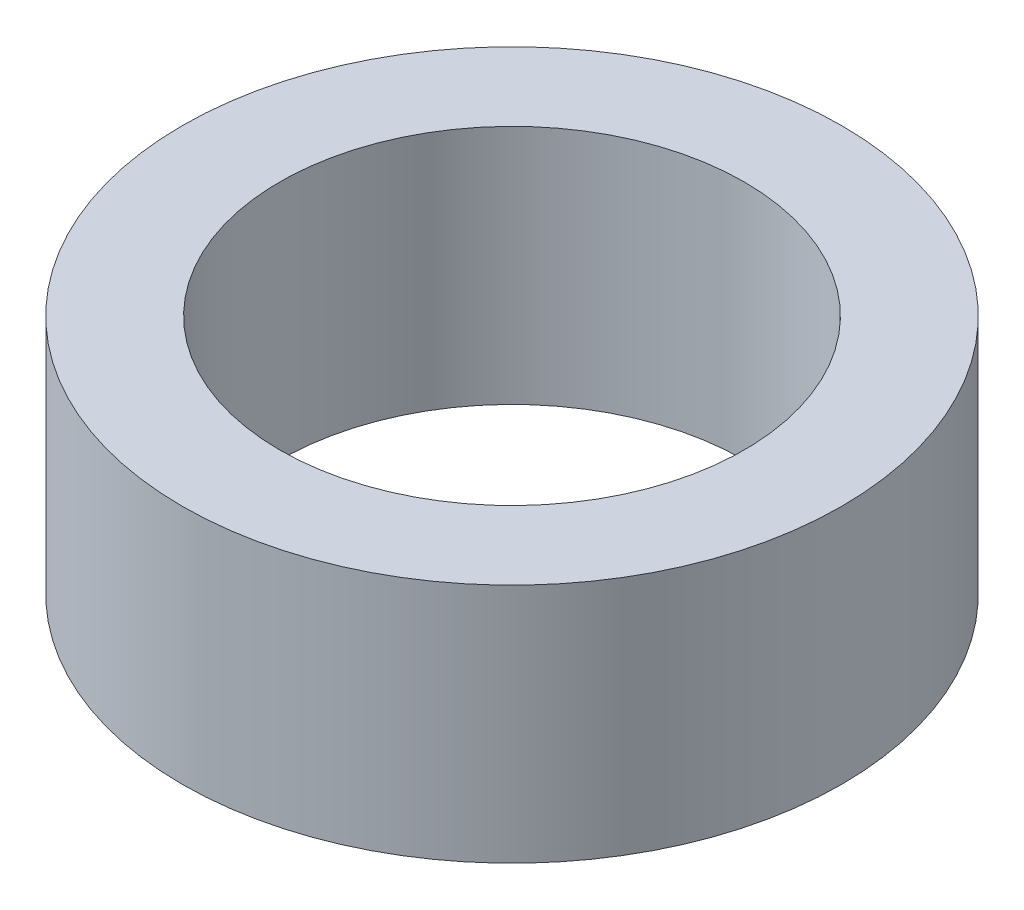
from build123d import *

# Parameters (mm, degrees)
SKETCH1_R           = 57.5
SKETCH1_R_2         = 40.5
BOSS_EXTRUDE1_DEPTH = 42


with BuildPart() as part:
    # Sketch1 → Boss-Extrude1 (new body)
    with BuildSketch(Plane(origin=(0, 0, 0), x_dir=(1, 0, 0), z_dir=(0, 1, 0))):
        Circle(SKETCH1_R)
        Circle(SKETCH1_R_2, mode=Mode.SUBTRACT)
    extrude(amount=BOSS_EXTRUDE1_DEPTH)


solid = part.part
